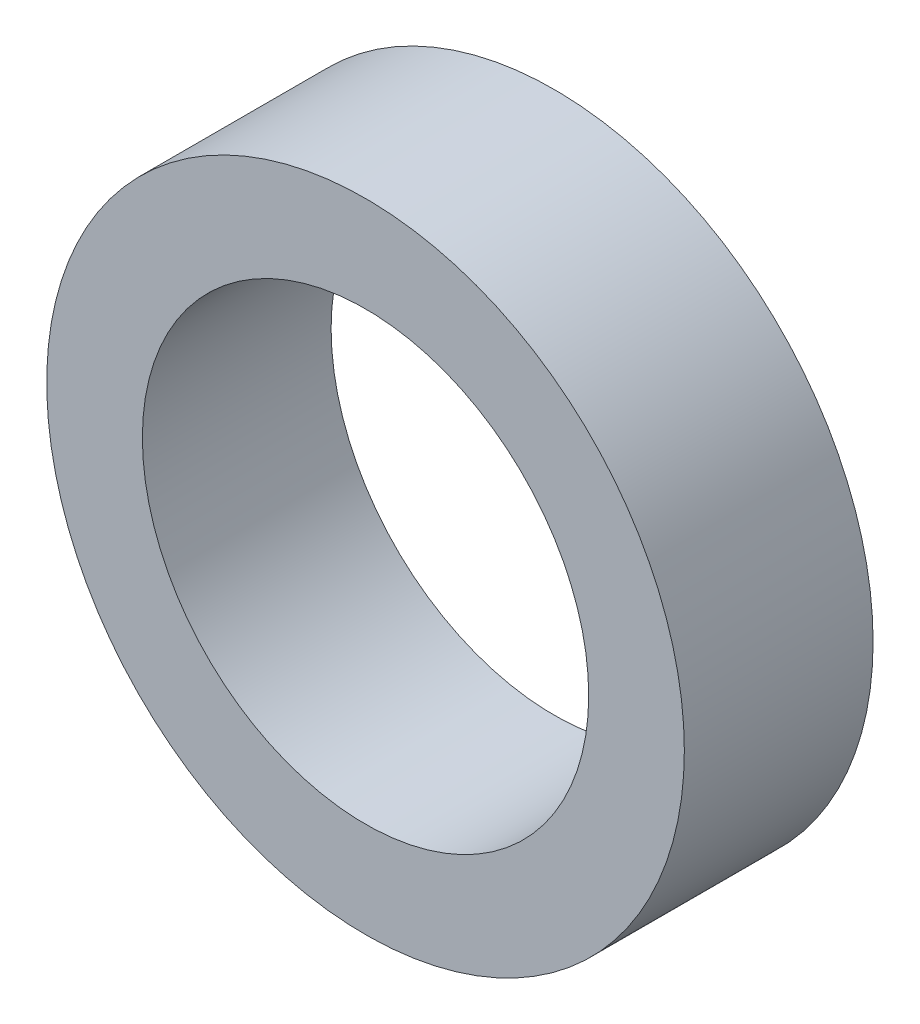
from build123d import *

# Parameters (mm, degrees)
SKETCH1_R           = 15.875
SKETCH1_R_2         = 11.1125
BOSS_EXTRUDE1_DEPTH = 4.699


with BuildPart() as part:
    # Sketch1 → Boss-Extrude1 (new body, symmetric)
    with BuildSketch(Plane.XY):
        Circle(SKETCH1_R)
        Circle(SKETCH1_R_2, mode=Mode.SUBTRACT)
    extrude(amount=BOSS_EXTRUDE1_DEPTH, both=True)


solid = part.part
